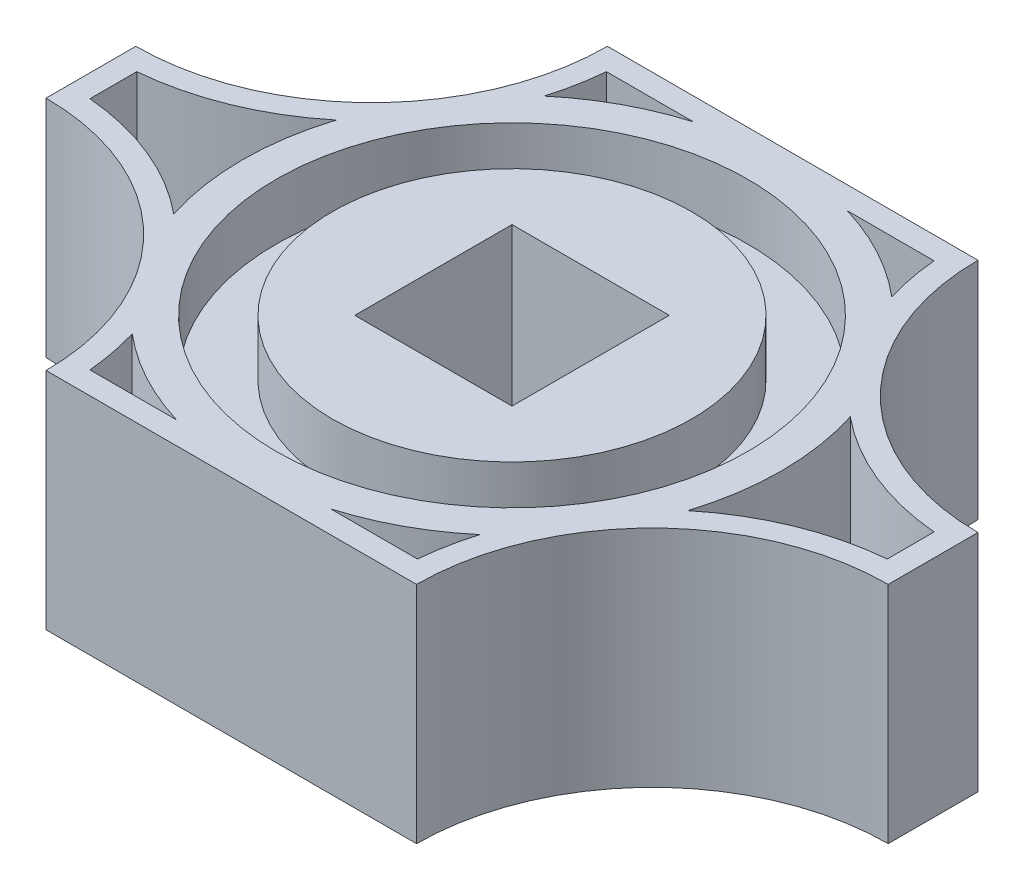
from build123d import *

# Parameters (mm, degrees)
SKETCH1_W           = 75
SKETCH1_H           = 50
BOSS_EXTRUDE1_DEPTH = 20
SKETCH2_R           = 21
SKETCH2_R_2         = 16
CUT_EXTRUDE1_DEPTH  = 5
SKETCH3_W           = 14
SKETCH3_H           = 14
CUT_EXTRUDE2_DEPTH  = 21
CUT_EXTRUDE3_DEPTH  = 21
CUT_EXTRUDE6_DEPTH  = 10


with BuildPart() as part:
    # Sketch1 → Boss-Extrude1 (new body)
    with BuildSketch(Plane(origin=(0, 0, 0), x_dir=(1, 0, 0), z_dir=(0, 1, 0))):
        with Locations((37.5, 25)):
            Rectangle(SKETCH1_W, SKETCH1_H)
    extrude(amount=BOSS_EXTRUDE1_DEPTH)

    # Sketch2 → Cut-Extrude1 (cut)
    with BuildSketch(Plane(origin=(0, 20, 0), x_dir=(1, 0, 0), z_dir=(0, 1, 0))):
        with Locations((37.5, 25)):
            Circle(SKETCH2_R)
        with Locations((37.5, 25)):
            Circle(SKETCH2_R_2, mode=Mode.SUBTRACT)
    extrude(amount=-CUT_EXTRUDE1_DEPTH, mode=Mode.SUBTRACT)

    # Sketch3 → Cut-Extrude2 (cut, through all)
    with BuildSketch(Plane(origin=(0, 20, 0), x_dir=(1, 0, 0), z_dir=(0, 1, 0))):
        with Locations((37.5, 25)):
            Rectangle(SKETCH3_W, SKETCH3_H)
    extrude(amount=-CUT_EXTRUDE2_DEPTH, mode=Mode.SUBTRACT)

    # Sketch4 → Cut-Extrude3 (cut, through all)
    with BuildSketch(Plane.XZ):
        with BuildLine():
            Line((0, -29), (0, -50))
            Line((0, -50), (21, -50))
            ThreePointArc((21, -50), (14.849242405, -35.150757595), (0, -29))
        make_face()
        with BuildLine():
            Line((75, -29), (75, -50))
            Line((75, -50), (54, -50))
            ThreePointArc((54, -50), (60.150757595, -35.150757595), (75, -29))
        make_face()
        with BuildLine():
            Line((75, -21), (75, 0))
            Line((75, 0), (54, 0))
            ThreePointArc((54, 0), (60.150757595, -14.849242405), (75, -21))
        make_face()
        with BuildLine():
            Line((0, 0), (21, 0))
            ThreePointArc((21, 0), (14.849242405, -14.849242405), (0, -21))
            Line((0, -21), (0, 0))
        make_face()
    extrude(amount=-CUT_EXTRUDE3_DEPTH, mode=Mode.SUBTRACT)

    # Sketch6 → Cut-Extrude6 (cut)
    with BuildSketch(Plane(origin=(0, 20, 0), x_dir=(1, 0, 0), z_dir=(0, 1, 0))):
        with BuildLine():
            Line((30.6443454, 48), (22.912878475, 48))
            ThreePointArc((22.912878475, 48), (22.583722585, 45.643915266), (22.012955919, 43.334433878))
            ThreePointArc((22.012955919, 43.334433878), (26.087685471, 46.113007296), (30.6443454, 48))
        make_face()
        with BuildLine():
            Line((44.3556546, 2), (52.087121525, 2))
            ThreePointArc((52.087121525, 2), (52.416277415, 4.356084734), (52.987044081, 6.665566122))
            ThreePointArc((52.987044081, 6.665566122), (48.912314529, 3.886992704), (44.3556546, 2))
        make_face()
        with BuildLine():
            Line((2, 27.087121525), (2, 22.912878475))
            ThreePointArc((2, 22.912878475), (8.700524902, 21.29086345), (14.619351774, 17.755972339))
            ThreePointArc((14.619351774, 17.755972339), (13.5, 25), (14.619351774, 32.244027661))
            ThreePointArc((14.619351774, 32.244027661), (8.700524902, 28.70913655), (2, 27.087121525))
        make_face()
        with BuildLine():
            Line((22.912878475, 2), (30.6443454, 2))
            ThreePointArc((30.6443454, 2), (26.087685471, 3.886992704), (22.012955919, 6.665566122))
            ThreePointArc((22.012955919, 6.665566122), (22.583722585, 4.356084734), (22.912878475, 2))
        make_face()
        with BuildLine():
            Line((73, 22.912878475), (73, 27.087121525))
            ThreePointArc((73, 27.087121525), (66.299475098, 28.70913655), (60.380648226, 32.244027661))
            ThreePointArc((60.380648226, 32.244027661), (61.5, 25), (60.380648226, 17.755972339))
            ThreePointArc((60.380648226, 17.755972339), (66.299475098, 21.29086345), (73, 22.912878475))
        make_face()
        with BuildLine():
            Line((52.087121525, 48), (44.3556546, 48))
            ThreePointArc((44.3556546, 48), (48.912314529, 46.113007296), (52.987044081, 43.334433878))
            ThreePointArc((52.987044081, 43.334433878), (52.416277415, 45.643915266), (52.087121525, 48))
        make_face()
    extrude(amount=-CUT_EXTRUDE6_DEPTH, mode=Mode.SUBTRACT)


solid = part.part
